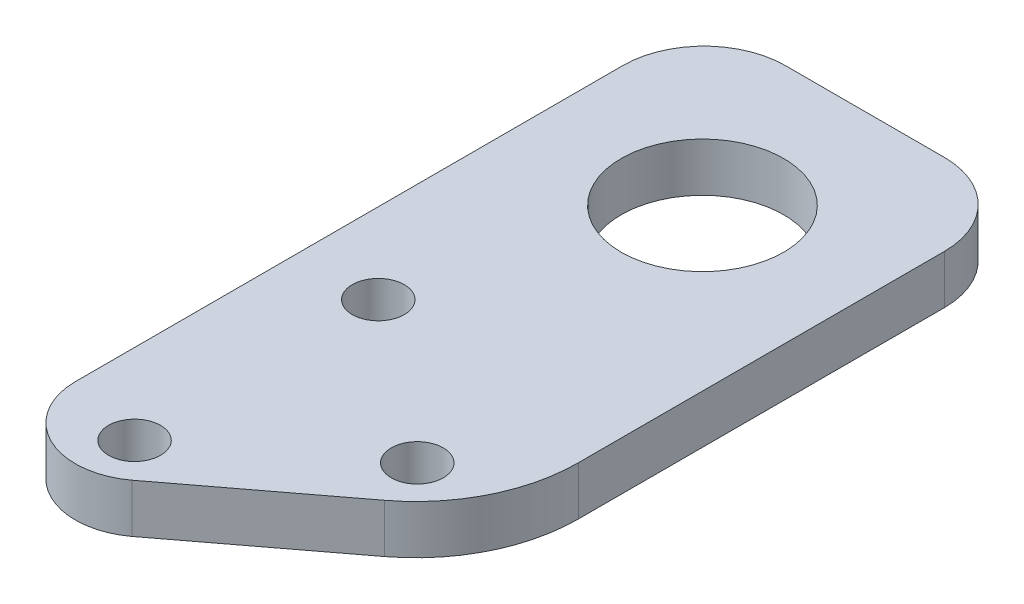
from build123d import *

# Parameters (mm, degrees)
SKETCH1_R           = 1.6
SKETCH1_R_2         = 5
BOSS_EXTRUDE1_DEPTH = 3


with BuildPart() as part:
    # Sketch1 → Boss-Extrude1 (new body)
    with BuildSketch(Plane(origin=(0, 0, 0), x_dir=(1, 0, 0), z_dir=(0, 1, 0))):
        with BuildLine():
            Line((-9.9, 27.5), (-9.9, -6.192201576))
            ThreePointArc((-9.9, -6.192201576), (-7.485730167, -10.104724514), (-2.905997097, -9.701512952))
            Line((-2.905997097, -9.701512952), (5.93857688, -3.001078121))
            ThreePointArc((5.93857688, -3.001078121), (8.855047984, 0.519324784), (9.9, 4.96984336))
            Line((9.9, 4.96984336), (9.9, 27.5))
            ThreePointArc((9.9, 27.5), (8.435533906, 31.035533906), (4.9, 32.5))
            Line((4.9, 32.5), (-4.9, 32.5))
            ThreePointArc((-4.9, 32.5), (-8.435533906, 31.035533906), (-9.9, 27.5))
        make_face()
        with Locations((-4.95, 7.5)):
            Circle(SKETCH1_R, mode=Mode.SUBTRACT)
        with Locations((-4.95, -7.5)):
            Circle(SKETCH1_R, mode=Mode.SUBTRACT)
        with Locations((4.95, 0)):
            Circle(SKETCH1_R, mode=Mode.SUBTRACT)
        with Locations((0, 22.5)):
            Circle(SKETCH1_R_2, mode=Mode.SUBTRACT)
    extrude(amount=BOSS_EXTRUDE1_DEPTH)


solid = part.part
